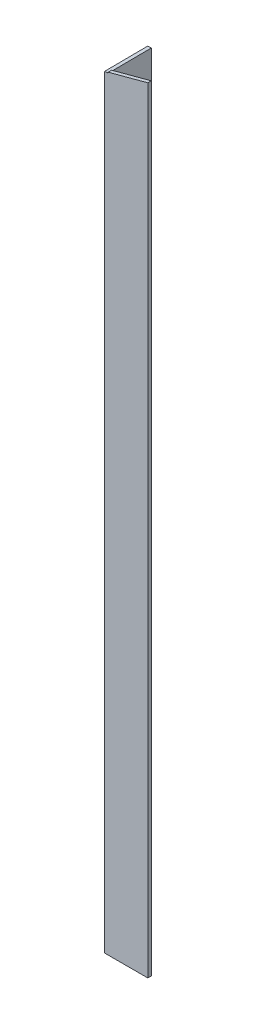
from build123d import *

# Parameters (mm, degrees)
EXTRUDE_1_DEPTH     = 900
CUT_EXTRUDE_1_DEPTH = 4
CUT_EXTRUDE_2_DEPTH = 4


with BuildPart() as part:
    # Эскиз1 → Вытянуть-Тонкостенный1 (new body)
    with BuildSketch(Plane(origin=(0, 0, 0), x_dir=(1, 0, 0), z_dir=(0, 1, 0))):
        Polygon((0, 50), (0, 0), (50, 0), (50, 4), (4, 4), (4, 50), align=None)
    extrude(amount=EXTRUDE_1_DEPTH)

    # Эскиз3 → Вырез-Вытянуть1 (cut)
    with BuildSketch(Plane.XY):
        Polygon((0, 900), (50, 900), (0, 886.602540378), align=None)
    extrude(amount=-CUT_EXTRUDE_1_DEPTH, mode=Mode.SUBTRACT)

    # Эскиз4 → Вырез-Вытянуть2 (cut)
    with BuildSketch(Plane.ZY):
        Polygon((0, 900), (-50, 900), (-50, 887), (0, 886.602540378), align=None)
    extrude(amount=-CUT_EXTRUDE_2_DEPTH, mode=Mode.SUBTRACT)


solid = part.part
